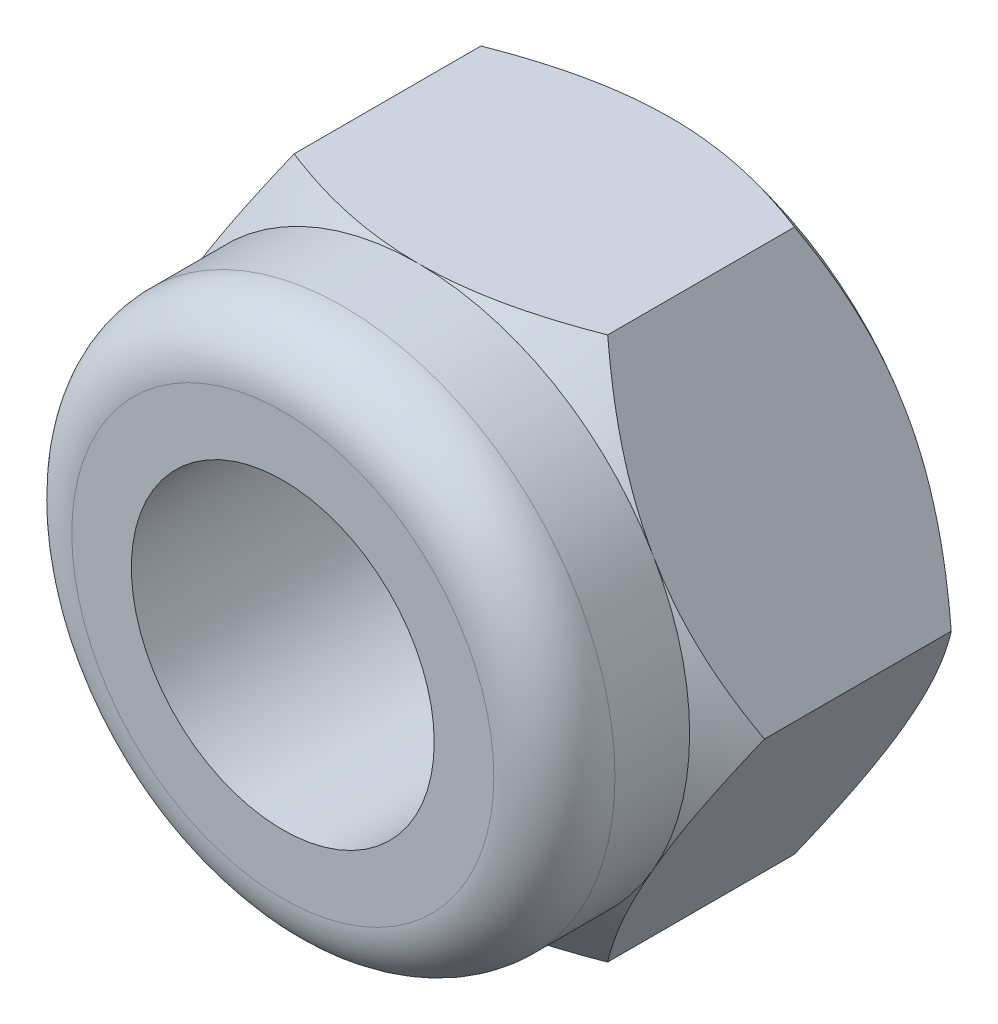
from build123d import *

# Parameters (mm, degrees)
SKETCH1_R           = 1.5
BOSS_EXTRUDE1_DEPTH = 2.5
SKETCH2_R           = 2.69
SKETCH2_R_2         = 1.5
BOSS_EXTRUDE2_DEPTH = 1.34
FILLET1_R           = 0.6
CHAMFER1_SIZE       = 0.3


with BuildPart() as part:
    # Sketch1 → Boss-Extrude1 (new body)
    with BuildSketch(Plane.XY):
        Polygon((-1.553072224, 2.69), (1.553072224, 2.69), (3.106144448, 0), (1.553072224, -2.69), (-1.553072224, -2.69), (-3.106144448, 0), align=None)
        Circle(SKETCH1_R, mode=Mode.SUBTRACT)
    extrude(amount=BOSS_EXTRUDE1_DEPTH)

    # Sketch2 → Boss-Extrude2 (add)
    with BuildSketch(Plane.XY.offset(2.5)):
        Circle(SKETCH2_R)
        Circle(SKETCH2_R_2, mode=Mode.SUBTRACT)
    extrude(amount=BOSS_EXTRUDE2_DEPTH)

    # Fillet1
    fillet1_edges = [part.edges().sort_by_distance(p)[0] for p in [
        (-2.69, 0, 3.84),
    ]]
    fillet(fillet1_edges, radius=FILLET1_R)

    # Sketch3 → Cut-Revolve1 (revolve, cut)
    with BuildSketch(Plane(origin=(0, 0, 0), x_dir=(0, 0, -1), z_dir=(1, 0, 0))):
        Polygon((-2.5, 2.69), (-2.109788941, 3.19), (-0.390211059, 3.19), (0, 2.69), (0, 3.325081684), (-2.5, 3.325081684), align=None)
    revolve(axis=Axis((0, 0, 0), (0, 0, -1)), mode=Mode.SUBTRACT)

    # Chamfer1
    chamfer1_edges = [part.edges().sort_by_distance(p)[0] for p in [
        (-1.5, 0, 0),
    ]]
    chamfer(chamfer1_edges, length=CHAMFER1_SIZE)


solid = part.part
